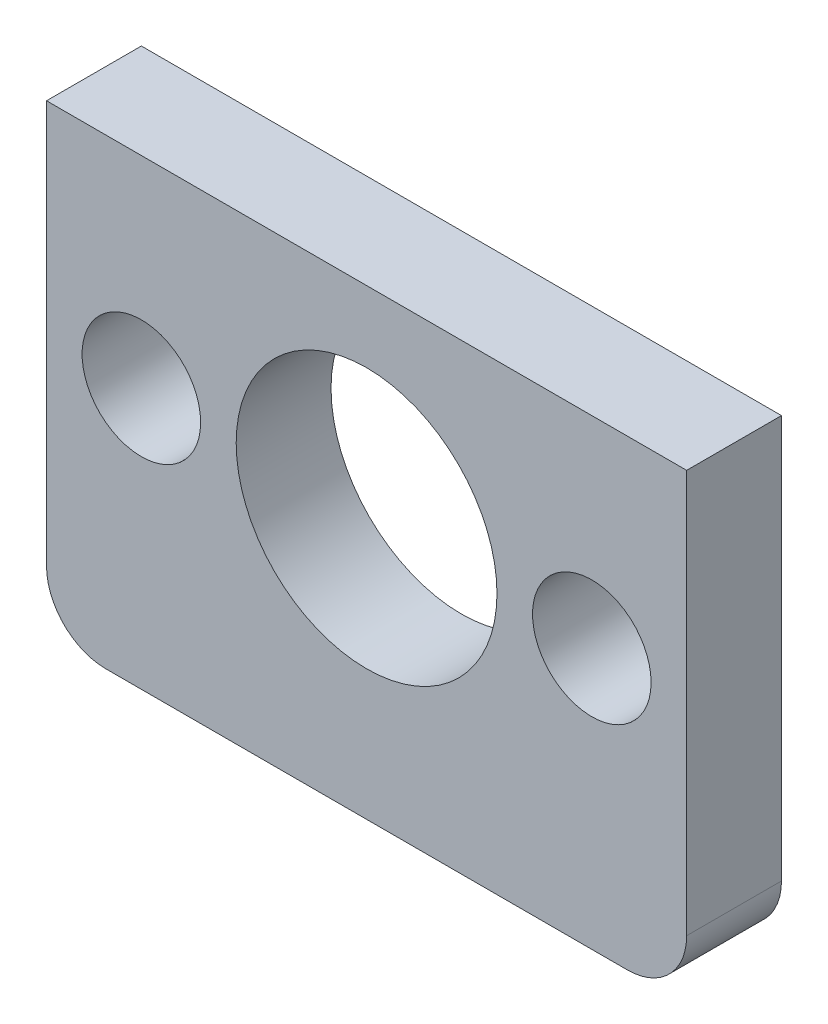
from build123d import *

# Parameters (mm, degrees)
SKETCH1_R           = 5
SKETCH1_R_2         = 11
BOSS_EXTRUDE1_DEPTH = 8


with BuildPart() as part:
    # Sketch1 → Boss-Extrude1 (new body)
    with BuildSketch(Plane.XY):
        with BuildLine():
            Line((-22, -22), (22, -22))
            ThreePointArc((22, -22), (25.535533906, -20.535533906), (27, -17))
            Line((27, -17), (27, 17))
            Line((27, 17), (-27, 17))
            Line((-27, 17), (-27, -17))
            ThreePointArc((-27, -17), (-25.535533906, -20.535533906), (-22, -22))
        make_face()
        with Locations((-19, 0)):
            Circle(SKETCH1_R, mode=Mode.SUBTRACT)
        with Locations((19, 0)):
            Circle(SKETCH1_R, mode=Mode.SUBTRACT)
        Circle(SKETCH1_R_2, mode=Mode.SUBTRACT)
    extrude(amount=BOSS_EXTRUDE1_DEPTH)


solid = part.part
